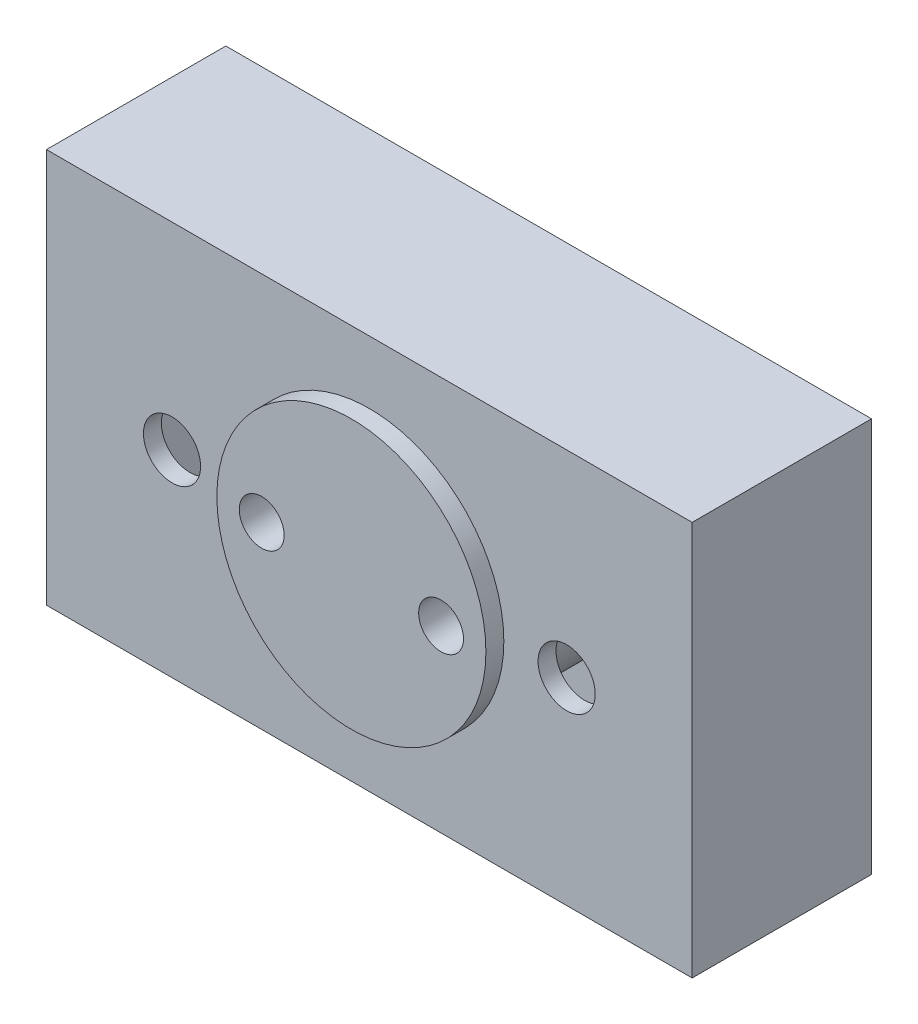
from build123d import *

# Parameters (mm, degrees)
SKETCH1_W          = 228.6
SKETCH1_H          = 139.7
EXTRUDE1_DEPTH     = 6.35
SKETCH1_3_W        = 228.6
SKETCH1_3_H        = 139.7
SKETCH1_3_W_2      = 215.9
SKETCH1_3_H_2      = 127
EXTRUDE2_DEPTH     = 50.8
SKETCH1_6_R        = 47.625
SKETCH1_6_R_2      = 7.9375
EXTRUDE4_DEPTH     = 63.5
SKETCH16_W         = 228.6
SKETCH16_H         = 139.7
EXTRUDE3_DEPTH     = 6.35
SKETCH1_5_R        = 10.1203125
SKETCH1_5_R_2      = 7.9375
CUT_EXTRUDE2_DEPTH = 57.15


with BuildPart() as part:
    # Sketch1 → Extrude1 (new body)
    with BuildSketch(Plane.XY):
        Rectangle(SKETCH1_W, SKETCH1_H)
    extrude(amount=-EXTRUDE1_DEPTH)

    # Sketch1_3 → Extrude2 (add)
    with BuildSketch(Plane.XY):
        Rectangle(SKETCH1_3_W, SKETCH1_3_H)
        Rectangle(SKETCH1_3_W_2, SKETCH1_3_H_2, mode=Mode.SUBTRACT)
    extrude(amount=EXTRUDE2_DEPTH)

    # Sketch1_6 → Extrude4 (add)
    with BuildSketch(Plane.XY):
        with Locations(Location((0, 0, 0), (0, 0, 180))):
            Circle(SKETCH1_6_R)
        with Locations((-31.75, 0)):
            Circle(SKETCH1_6_R_2, mode=Mode.SUBTRACT)
        with Locations((31.75, 0)):
            Circle(SKETCH1_6_R_2, mode=Mode.SUBTRACT)
    extrude(amount=EXTRUDE4_DEPTH)

    # Sketch16 → Extrude3 (add)
    with BuildSketch(Plane.XY.offset(50.8)):
        Rectangle(SKETCH16_W, SKETCH16_H)
    extrude(amount=EXTRUDE3_DEPTH)

    # Sketch1_5 → Cut-Extrude2 (cut)
    with BuildSketch(Plane.XY):
        with Locations((-69.85, 0)):
            Circle(SKETCH1_5_R)
        with Locations((-31.75, 0)):
            Circle(SKETCH1_5_R_2)
        with Locations((69.85, 0)):
            Circle(SKETCH1_5_R)
        with Locations((31.75, 0)):
            Circle(SKETCH1_5_R_2)
    extrude(amount=CUT_EXTRUDE2_DEPTH, mode=Mode.SUBTRACT)


solid = part.part
